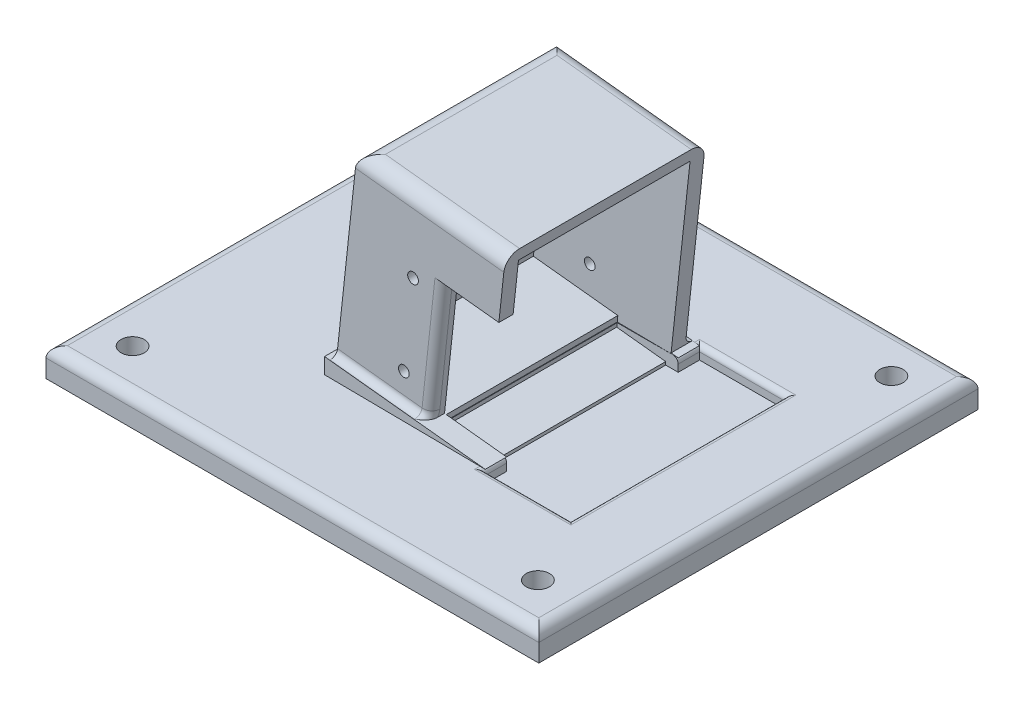
from build123d import *

# Parameters (mm, degrees)
SKETCH1_W           = 138
SKETCH1_H           = 8
BOSS_EXTRUDE1_DEPTH = 123
SKETCH2_R           = 3.25
CUT_EXTRUDE1_DEPTH  = 163.694989079
BOSS_EXTRUDE2_DEPTH = 60
BOSS_EXTRUDE3_DEPTH = 49.45
SKETCH6_R           = 1.5
CUT_EXTRUDE2_DEPTH  = 153.033158476
CUT_EXTRUDE3_DEPTH  = 4
SKETCH9_R           = 15.125
CUT_EXTRUDE4_DEPTH  = 3
SKETCH10_W          = 15
SKETCH10_H          = 48.05
CUT_EXTRUDE5_DEPTH  = 3
SKETCH11_W          = 56.05
SKETCH11_H          = 3
BOSS_EXTRUDE4_DEPTH = 41.8
SKETCH12_W          = 23.99
SKETCH12_H          = 60
CUT_EXTRUDE6_DEPTH  = 3.5
FILLET1_R           = 4
FILLET3_R           = 3
FILLET5_R           = 1.9
FILLET6_R           = 1.9
FILLET7_R           = 2.5
SKETCH13_W          = 2
SKETCH13_H          = 48.05
CUT_EXTRUDE7_DEPTH  = 3.5
SKETCH14_W          = 48.05
SKETCH14_H          = 3.5
CUT_EXTRUDE8_DEPTH  = 3.5
FILLET8_R           = 1.5


with BuildPart() as part:
    # Sketch1 → Boss-Extrude1 (new body)
    with BuildSketch(Plane.XY):
        with Locations((37.191616766, 4)):
            Rectangle(SKETCH1_W, SKETCH1_H)
    extrude(amount=-BOSS_EXTRUDE1_DEPTH)

    # Sketch2 → Cut-Extrude1 (cut, through all)
    with BuildSketch(Plane(origin=(0, 8, 0), x_dir=(1, 0, 0), z_dir=(0, 1, 0))):
        with Locations(Location((-19.558383234, 12, 0), (0, 0, 180))):
            Circle(SKETCH2_R)
        with Locations(Location((93.941616766, 12, 0), (0, 0, 180))):
            Circle(SKETCH2_R)
        with Locations(Location((93.941616766, 111, 0), (0, 0, 180))):
            Circle(SKETCH2_R)
        with Locations(Location((-19.558383234, 111, 0), (0, 0, 180))):
            Circle(SKETCH2_R)
    extrude(amount=-CUT_EXTRUDE1_DEPTH, mode=Mode.SUBTRACT)


with BuildPart() as body_2:
    # Sketch3 → Boss-Extrude2 (new body)
    with BuildSketch(Plane.XY.offset(-31.5)):
        Polygon((14.691616766, 8.436407474), (59.691616766, 8), (14.691616766, 12.856407474), align=None)
    extrude(amount=-BOSS_EXTRUDE2_DEPTH)

    # Sketch5 → Boss-Extrude3 (add)
    with BuildSketch(Plane(origin=(1.540632023, 14.275663932, 0), x_dir=(0.9942269978025435, -0.10729714274173967, 0), z_dir=(0.10729714274173965, 0.9942269978025434, 0))):
        Polygon((56.48863979, 33.5), (14.68863979, 33.5), (14.68863979, 89.55), (56.48863979, 89.55), (56.48863979, 85.55), (17.68863979, 85.55), (17.68863979, 37.5), (56.48863979, 37.5), align=None)
    extrude(amount=BOSS_EXTRUDE3_DEPTH)

    # Sketch6 → Cut-Extrude2 (cut, through all)
    with BuildSketch(Plane.XY.offset(-33.5)):
        with Locations((34.906517302, 18.41952228)):
            Circle(SKETCH6_R)
        with Locations((37.481648728, 42.280970227)):
            Circle(SKETCH6_R)
    extrude(amount=-CUT_EXTRUDE2_DEPTH, mode=Mode.SUBTRACT)

    # Sketch8 → Cut-Extrude3 (cut)
    with BuildSketch(Plane(origin=(0, 0, -37.5), x_dir=(-1, 0, 0), z_dir=(0, 0, -1))):
        Polygon((-57.703162771, 8.214594285), (-42.292644305, 9.877699998), (-46.101692872, 45.17275842), (-61.512211338, 43.509652707), align=None)
    extrude(amount=-CUT_EXTRUDE3_DEPTH, mode=Mode.SUBTRACT)

    # Sketch9 → Cut-Extrude4 (cut)
    with BuildSketch(Plane(origin=(14.60384224, -1.57604908, 0), x_dir=(0, 0, 1), z_dir=(-0.9942269978025434, 0.10729714274173965, 0))):
        with Locations(Location((-60.55, 34.358555907, 0), (0, 0, 270))):
            Circle(SKETCH9_R)
    extrude(amount=-CUT_EXTRUDE4_DEPTH, mode=Mode.SUBTRACT)


with BuildPart() as cut_extrude5_tool:
    # Sketch10 → Cut-Extrude5 (new body)
    with BuildSketch(Plane(origin=(1.540632023, 14.275663932, 0), x_dir=(0.9942269978025435, -0.10729714274173967, 0), z_dir=(0.10729714274173965, 0.9942269978025434, 0))):
        with Locations((48.98863979, 61.525)):
            Rectangle(SKETCH10_W, SKETCH10_H)
    extrude(amount=-CUT_EXTRUDE5_DEPTH)


with BuildPart() as part_1:
    add(part.part)

    # Cut-Extrude5: cut by cut_extrude5_tool
    add(cut_extrude5_tool.part, mode=Mode.SUBTRACT)

    # Sketch12 → Cut-Extrude6 (cut)
    with BuildSketch(Plane(origin=(0, 8, 0), x_dir=(1, 0, 0), z_dir=(0, 1, 0))):
        with Locations((71.686616766, 61.5)):
            Rectangle(SKETCH12_W, SKETCH12_H)
    extrude(amount=-CUT_EXTRUDE6_DEPTH, mode=Mode.SUBTRACT)

    # Fillet3
    fillet3_edges = [part_1.edges().sort_by_distance(p)[0] for p in [
        (37.191616766, 8, -123),
        (37.191616766, 8, 0),
        (-31.808383234, 8, -61.5),
        (106.191616766, 8, -61.5),
    ]]
    fillet(fillet3_edges, radius=FILLET3_R)


with BuildPart() as body_2_1:
    add(body_2.part)

    # Cut-Extrude5: cut by cut_extrude5_tool
    add(cut_extrude5_tool.part, mode=Mode.SUBTRACT)

    # Sketch11 → Boss-Extrude4 (add)
    with BuildSketch(Plane(origin=(14.60384224, -1.57604908, 0), x_dir=(0, 0, 1), z_dir=(-0.9942269978025434, 0.10729714274173965, 0))):
        with Locations((-61.525, 65.308555907)):
            Rectangle(SKETCH11_W, SKETCH11_H)
    extrude(amount=-BOSS_EXTRUDE4_DEPTH)

    # Fillet1
    fillet1_edges = [body_2_1.edges().sort_by_distance(p)[0] for p in [
        (42.551553654, 62.604310604, -89.55),
        (42.551553654, 62.604310604, -33.5),
        (21.7722094, 64.846820887, -61.525),
    ]]
    fillet(fillet1_edges, radius=FILLET1_R)

    # Fillet5
    fillet5_edges = [body_2_1.edges().sort_by_distance(p)[0] for p in [
        (29.218559284, 11.288657425, -33.5),
    ]]
    fillet(fillet5_edges, radius=FILLET5_R)

    # Fillet6
    fillet6_edges = [body_2_1.edges().sort_by_distance(p)[0] for p in [
        (36.923818517, 10.457104569, -89.55),
    ]]
    fillet(fillet6_edges, radius=FILLET6_R)

    # Fillet7
    fillet7_edges = [body_2_1.edges().sort_by_distance(p)[0] for p in [
        (44.299100874, 28.469744857, -33.5),
        (42.352354855, 10.430984455, -32.943502884),
    ]]
    fillet(fillet7_edges, radius=FILLET7_R)


with BuildPart() as cut_extrude7_tool:
    # Sketch13 → Cut-Extrude7 (new body)
    with BuildSketch(Plane(origin=(1.540632023, 14.275663932, 0), x_dir=(0.9942269978025435, -0.10729714274173967, 0), z_dir=(0.10729714274173965, 0.9942269978025434, 0))):
        with Locations((57.48863979, 61.525)):
            Rectangle(SKETCH13_W, SKETCH13_H)
    extrude(amount=-CUT_EXTRUDE7_DEPTH)


with BuildPart() as part_2:
    add(part_1.part)

    # Cut-Extrude7: cut by cut_extrude7_tool
    add(cut_extrude7_tool.part, mode=Mode.SUBTRACT)

    # Sketch14 → Cut-Extrude8 (cut)
    with BuildSketch(Plane(origin=(59.691616766, 0, 0), x_dir=(0, 0, -1), z_dir=(1, 0, 0))):
        with Locations((61.525, 6.25)):
            Rectangle(SKETCH14_W, SKETCH14_H)
    extrude(amount=-CUT_EXTRUDE8_DEPTH, mode=Mode.SUBTRACT)

    # Fillet8
    fillet8_edges = [part_2.edges().sort_by_distance(p)[0] for p in [
        (59.691616766, 8, -88.525),
        (71.686616766, 8, -31.5),
        (83.681616766, 8, -61.5),
        (71.686616766, 8, -91.5),
        (59.691616766, 8, -34.5),
    ]]
    fillet(fillet8_edges, radius=FILLET8_R)


with BuildPart() as body_2_2:
    add(body_2_1.part)

    # Cut-Extrude7: cut by cut_extrude7_tool
    add(cut_extrude7_tool.part, mode=Mode.SUBTRACT)


solid = Compound([part_2.part, body_2_2.part])
